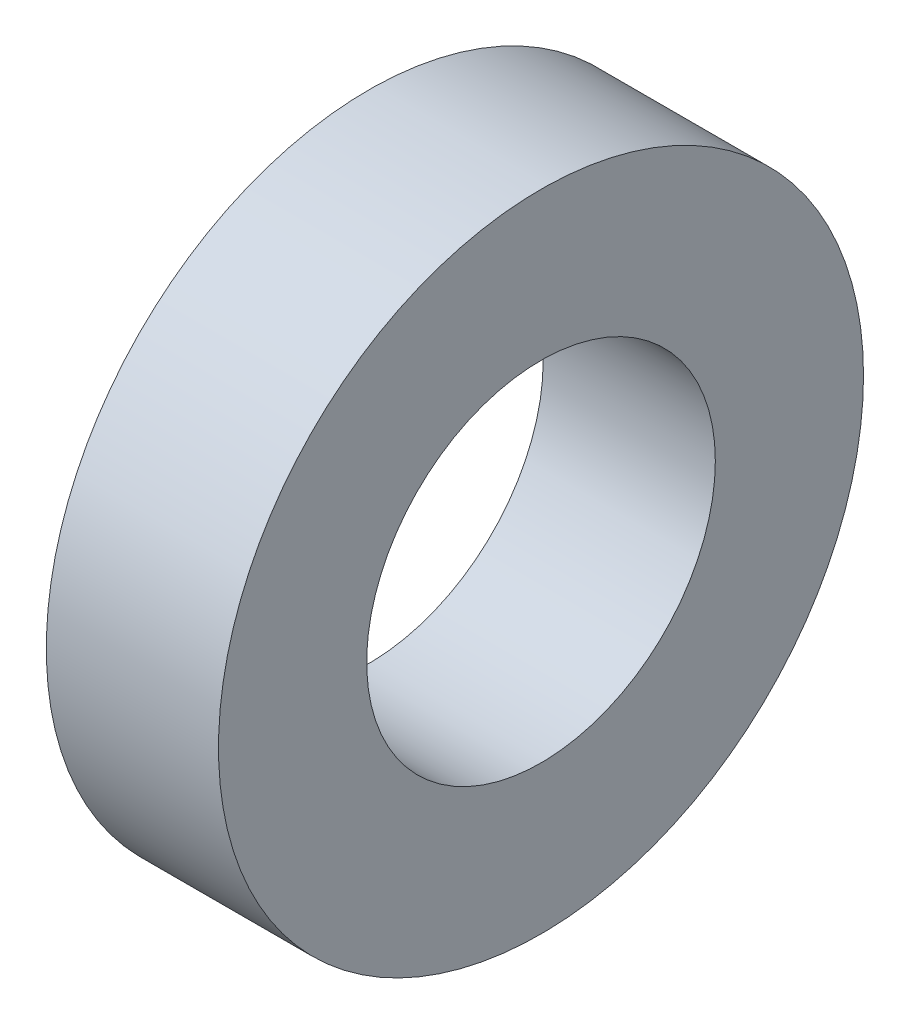
from build123d import *

# Parameters (mm, degrees)
SKETCH1_R           = 29.36875
SKETCH1_R_2         = 15.875
BOSS_EXTRUDE1_DEPTH = 7.84


with BuildPart() as part:
    # Sketch1 → Boss-Extrude1 (new body, symmetric)
    with BuildSketch(Plane(origin=(0, 0, 0), x_dir=(0, 0, -1), z_dir=(1, 0, 0))):
        Circle(SKETCH1_R)
        Circle(SKETCH1_R_2, mode=Mode.SUBTRACT)
    extrude(amount=BOSS_EXTRUDE1_DEPTH, both=True)


solid = part.part
